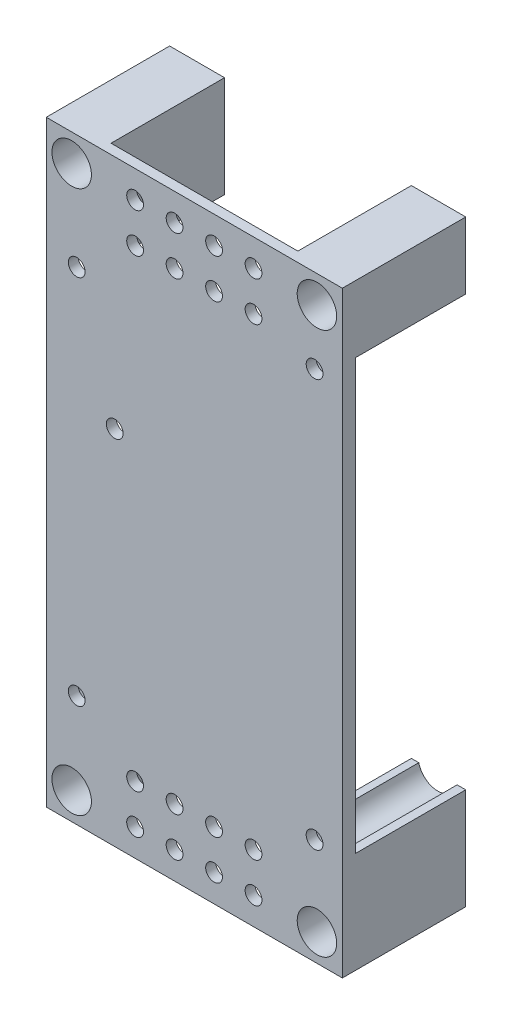
from build123d import *

# Parameters (mm, degrees)
ESQUISSE1_W                  = 60
ESQUISSE1_H                  = 121.051019192
ESQUISSE1_R                  = 4
ESQUISSE1_R_2                = 1.7
BOSS_EXTRU_1_DEPTH           = 25
ESQUISSE2_W                  = 22.3
ESQUISSE2_H                  = 80
ENL_V_MAT_EXTRU_1_DEPTH      = 1
ENL_V_MAT_EXTRU_1_DEPTH_BACK = 61
ESQUISSE3_R                  = 4
ENL_V_MAT_EXTRU_2_DEPTH      = 23
ESQUISSE4_W                  = 37.857644836
ESQUISSE4_H                  = 23
ENL_V_MAT_EXTRU_3_DEPTH      = 142
ESQUISSE5_R                  = 1.7
ENL_V_MAT_EXTRU_4_DEPTH      = 5
ESQUISSE6_W                  = 3.767049496
ESQUISSE6_H                  = 22.3
ENL_V_MAT_EXTRU_5_DEPTH      = 7


with BuildPart() as part:
    # Esquisse1 → Boss.-Extru.1 (new body)
    with BuildSketch(Plane.XY):
        with Locations((-13.883911806, 6.527624962)):
            Rectangle(ESQUISSE1_W, ESQUISSE1_H)
        with Locations((-38.733325391, -48.472375038)):
            Circle(ESQUISSE1_R, mode=Mode.SUBTRACT)
        with Locations((10.965501778, -48.472375038)):
            Circle(ESQUISSE1_R, mode=Mode.SUBTRACT)
        with Locations((10.965501778, 61.527624962)):
            Circle(ESQUISSE1_R, mode=Mode.SUBTRACT)
        with Locations((-38.733325391, 61.527624962)):
            Circle(ESQUISSE1_R, mode=Mode.SUBTRACT)
        with Locations((10.486674609, -32.532375038)):
            Circle(ESQUISSE1_R_2, mode=Mode.SUBTRACT)
        with Locations((10.486674609, 50.067624962)):
            Circle(ESQUISSE1_R_2, mode=Mode.SUBTRACT)
        with Locations((-30.013325391, 19.323966875)):
            Circle(ESQUISSE1_R_2, mode=Mode.SUBTRACT)
        with Locations((-37.713325391, -31.392375038)):
            Circle(ESQUISSE1_R_2, mode=Mode.SUBTRACT)
        with Locations((-37.713325391, 43.847624962)):
            Circle(ESQUISSE1_R_2, mode=Mode.SUBTRACT)
    extrude(amount=BOSS_EXTRU_1_DEPTH)

    # Esquisse2 → Enlèv. mat.-Extru.1 (cut, two sides)
    with BuildSketch(Plane(origin=(16.116088194, 0, 0), x_dir=(0, 0, -1), z_dir=(1, 0, 0))) as enl_v_mat_extru_1_sk:
        with Locations((-11.15, 6.527624962)):
            Rectangle(ESQUISSE2_W, ESQUISSE2_H)
    extrude(amount=ENL_V_MAT_EXTRU_1_DEPTH, mode=Mode.SUBTRACT)
    extrude(enl_v_mat_extru_1_sk.sketch, amount=-ENL_V_MAT_EXTRU_1_DEPTH_BACK, mode=Mode.SUBTRACT)

    # Esquisse3 → Enlèv. mat.-Extru.2 (cut)
    with BuildSketch(Plane(origin=(0, 0, 0), x_dir=(-1, 0, 0), z_dir=(0, 0, -1))):
        with Locations((-10.486674609, -32.532375038)):
            Circle(ESQUISSE3_R)
        with Locations((37.713325391, -31.392375038)):
            Circle(ESQUISSE3_R)
        with Locations((-10.486674609, 50.067624962)):
            Circle(ESQUISSE3_R)
        with Locations((37.713325391, 43.847624962)):
            Circle(ESQUISSE3_R)
    extrude(amount=-ENL_V_MAT_EXTRU_2_DEPTH, mode=Mode.SUBTRACT)

    # Esquisse4 → Enlèv. mat.-Extru.3 (cut)
    with BuildSketch(Plane.XZ.offset(53.997884634)):
        with Locations((-13.831213491, 11.5)):
            Rectangle(ESQUISSE4_W, ESQUISSE4_H)
    extrude(amount=-ENL_V_MAT_EXTRU_3_DEPTH, mode=Mode.SUBTRACT)

    # Esquisse5 → Enlèv. mat.-Extru.4 (cut)
    with BuildSketch(Plane.XY.offset(25)):
        with Locations((-9.883911806, 61.527624962)):
            Circle(ESQUISSE5_R)
        with Locations((-1.883911806, 61.527624962)):
            Circle(ESQUISSE5_R)
        with Locations((-1.883911806, 53.527624962)):
            Circle(ESQUISSE5_R)
        with Locations((-9.883911806, 53.527624962)):
            Circle(ESQUISSE5_R)
        with Locations((-17.883911806, 53.527624962)):
            Circle(ESQUISSE5_R)
        with Locations((-25.883911806, 53.527624962)):
            Circle(ESQUISSE5_R)
        with Locations((-25.883911806, 61.527624962)):
            Circle(ESQUISSE5_R)
        with Locations((-17.883911806, 61.527624962)):
            Circle(ESQUISSE5_R)
        with Locations((-17.883911806, -48.472375038)):
            Circle(ESQUISSE5_R)
        with Locations((-25.883911806, -48.472375038)):
            Circle(ESQUISSE5_R)
        with Locations((-25.883911806, -40.472375038)):
            Circle(ESQUISSE5_R)
        with Locations((-17.883911806, -40.472375038)):
            Circle(ESQUISSE5_R)
        with Locations((-9.883911806, -40.472375038)):
            Circle(ESQUISSE5_R)
        with Locations((-1.883911806, -40.472375038)):
            Circle(ESQUISSE5_R)
        with Locations((-1.883911806, -48.472375038)):
            Circle(ESQUISSE5_R)
        with Locations((-9.883911806, -48.472375038)):
            Circle(ESQUISSE5_R)
    extrude(amount=-ENL_V_MAT_EXTRU_4_DEPTH, mode=Mode.SUBTRACT)

    # Esquisse6 → Enlèv. mat.-Extru.5 (cut)
    with BuildSketch(Plane.XZ.offset(-46.527624962)):
        with Locations((14.232563446, 11.15)):
            Rectangle(ESQUISSE6_W, ESQUISSE6_H)
    extrude(amount=-ENL_V_MAT_EXTRU_5_DEPTH, mode=Mode.SUBTRACT)


solid = part.part
